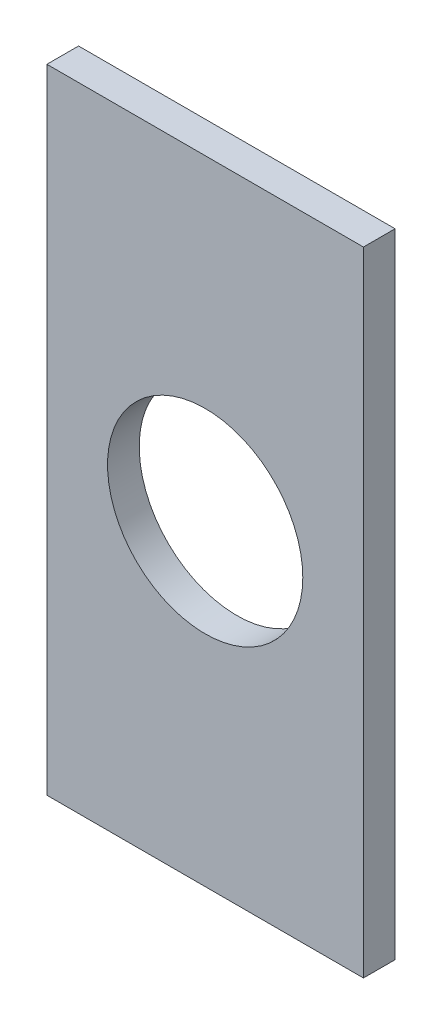
from build123d import *

# Parameters (mm, degrees)
SKETCH1_W           = 50
SKETCH1_H           = 100
BOSS_EXTRUDE1_DEPTH = 5
SKETCH2_R           = 15.421138397
CUT_EXTRUDE1_DEPTH  = 5


with BuildPart() as part:
    # Sketch1 → Boss-Extrude1 (new body)
    with BuildSketch(Plane.XY):
        Rectangle(SKETCH1_W, SKETCH1_H)
    extrude(amount=BOSS_EXTRUDE1_DEPTH)

    # Sketch2 → Cut-Extrude1 (cut)
    with BuildSketch(Plane.XY.offset(5)):
        Circle(SKETCH2_R)
    extrude(amount=-CUT_EXTRUDE1_DEPTH, mode=Mode.SUBTRACT)


solid = part.part
